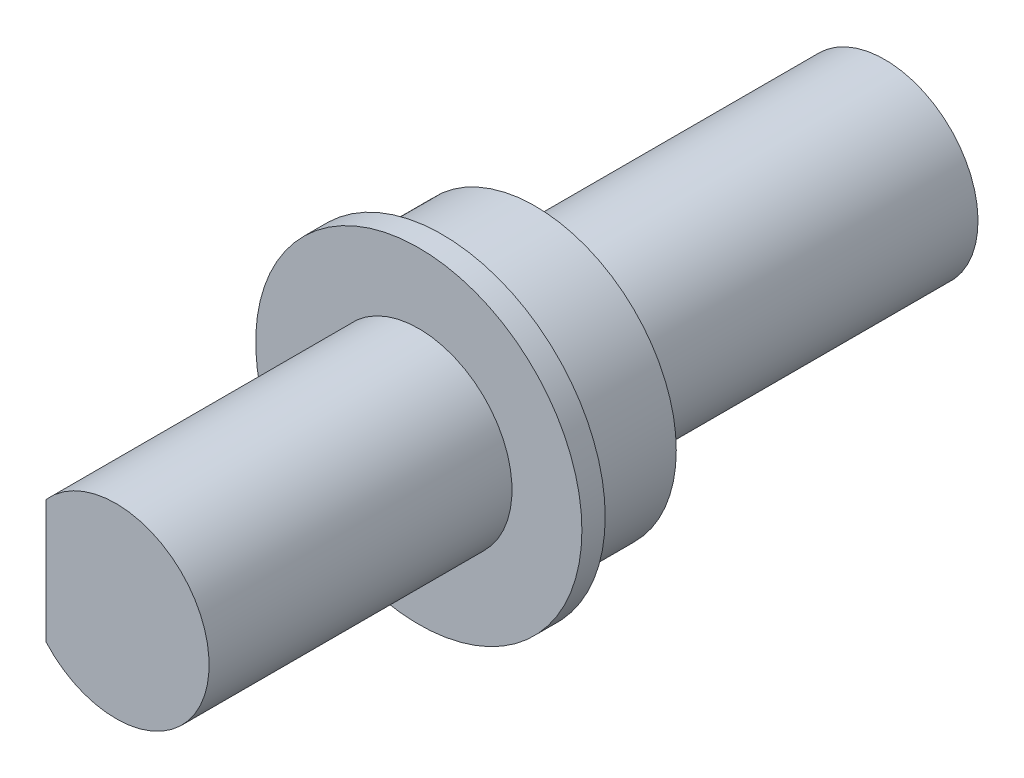
from build123d import *

# Parameters (mm, degrees)
SKETCH_1_R      = 6.05
EXTRUDE_1_DEPTH = 5
SKETCH_7_R      = 7
EXTRUDE_6_DEPTH = 1
EXTRUDE_2_DEPTH = 13
EXTRUDE_3_DEPTH = 15


with BuildPart() as part:
    # 草图1 → 凸台-拉伸1 (new body)
    with BuildSketch(Plane.XY):
        Circle(SKETCH_1_R)
    extrude(amount=EXTRUDE_1_DEPTH)

    # 草图7 → 凸台-拉伸6 (add)
    with BuildSketch(Plane.XY.offset(5)):
        Circle(SKETCH_7_R)
    extrude(amount=-EXTRUDE_6_DEPTH)

    # 草图2 → 凸台-拉伸2 (add)
    with BuildSketch(Plane.XY.offset(5)):
        with BuildLine():
            ThreePointArc((4, 0), (1.414213562, 3.741657387), (-3, 2.645751311))
            Line((-3, 2.645751311), (-3, -2.645751311))
            ThreePointArc((-3, -2.645751311), (1.414213562, -3.741657387), (4, 0))
        make_face()
    extrude(amount=EXTRUDE_2_DEPTH)

    # 草图4 → 凸台-拉伸3 (add)
    with BuildSketch(Plane(origin=(0, 0, 0), x_dir=(-1, 0, 0), z_dir=(0, 0, -1))):
        with BuildLine():
            ThreePointArc((4, 0), (-1.645751311, 3.645751311), (-2.645751311, -3))
            Line((-2.645751311, -3), (2.645751311, -3))
            ThreePointArc((2.645751311, -3), (3.645751311, -1.645751311), (4, 0))
        make_face()
    extrude(amount=EXTRUDE_3_DEPTH)


solid = part.part
